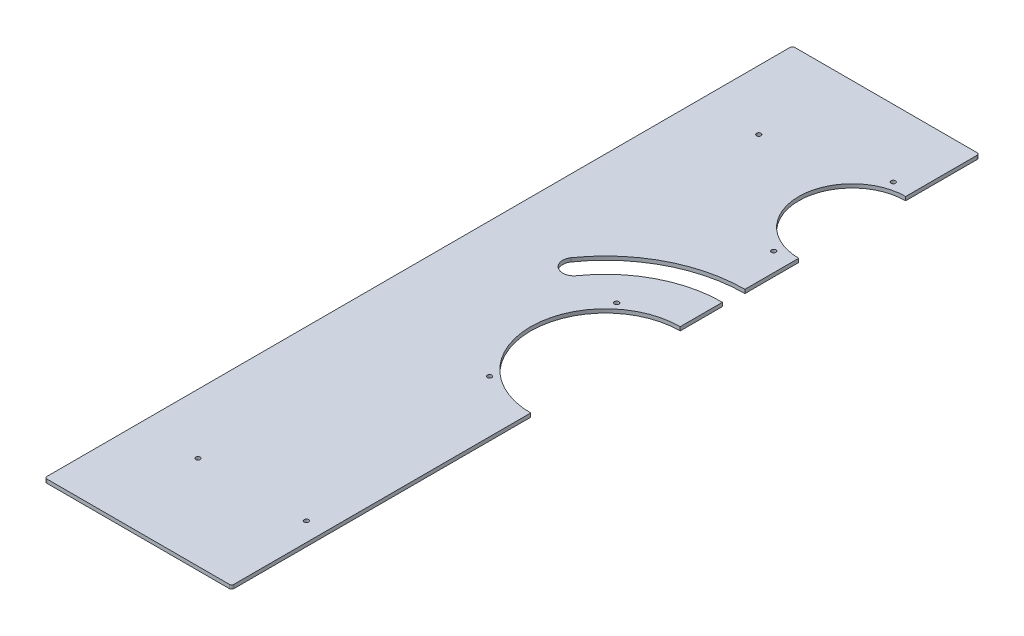
from build123d import *

# Parameters (mm, degrees)
SKETCH1_W           = 250
SKETCH1_H           = 1000
BOSS_EXTRUDE1_DEPTH = 5
FILLET1_R           = 3
CUT_EXTRUDE2_REACH  = 7
SKETCH3_R           = 71.5
SKETCH3_R_2         = 100
SKETCH3_R_3         = 3


with BuildPart() as part:
    # Sketch1 → Boss-Extrude1 (new body)
    with BuildSketch(Plane(origin=(0, 0, 0), x_dir=(1, 0, 0), z_dir=(0, 1, 0))):
        Rectangle(SKETCH1_W, SKETCH1_H)
    extrude(amount=BOSS_EXTRUDE1_DEPTH)

    # Fillet1
    fillet1_edges = [part.edges().sort_by_distance(p)[0] for p in [
        (125, 2.5, 500),
        (-125, 2.5, 500),
        (-125, 2.5, -500),
        (125, 2.5, -500),
    ]]
    fillet(fillet1_edges, radius=FILLET1_R)

    # Sketch3 → Cut-Extrude2 (cut, up to next)
    with BuildSketch(Plane(origin=(0, 5, 0), x_dir=(1, 0, 0), z_dir=(0, 1, 0)), mode=Mode.PRIVATE) as cut_extrude2_sk1:
        with Locations((125, 330)):
            Circle(SKETCH3_R)
    cut_extrude2_tool1 = extrude(cut_extrude2_sk1.sketch, amount=-CUT_EXTRUDE2_REACH, mode=Mode.PRIVATE) & part.part
    add(cut_extrude2_tool1.solids().sort_by_distance((125, 5, -330))[0], mode=Mode.SUBTRACT)
    # Sketch3 → Cut-Extrude2 (cut, up to next)
    with BuildSketch(Plane(origin=(0, 5, 0), x_dir=(1, 0, 0), z_dir=(0, 1, 0)), mode=Mode.PRIVATE) as cut_extrude2_sk2:
        with Locations((125, 0)):
            Circle(SKETCH3_R_2)
    cut_extrude2_tool2 = extrude(cut_extrude2_sk2.sketch, amount=-CUT_EXTRUDE2_REACH, mode=Mode.PRIVATE) & part.part
    add(cut_extrude2_tool2.solids().sort_by_distance((125, 5, 0))[0], mode=Mode.SUBTRACT)
    # Sketch3 → Cut-Extrude2 (cut, up to next)
    with BuildSketch(Plane(origin=(0, 5, 0), x_dir=(1, 0, 0), z_dir=(0, 1, 0)), mode=Mode.PRIVATE) as cut_extrude2_sk3:
        with Locations((-45, -375)):
            Circle(SKETCH3_R_3)
    cut_extrude2_tool3 = extrude(cut_extrude2_sk3.sketch, amount=-CUT_EXTRUDE2_REACH, mode=Mode.PRIVATE) & part.part
    add(cut_extrude2_tool3.solids().sort_by_distance((-45, 5, 375))[0], mode=Mode.SUBTRACT)
    # Sketch3 → Cut-Extrude2 (cut, up to next)
    with BuildSketch(Plane(origin=(0, 5, 0), x_dir=(1, 0, 0), z_dir=(0, 1, 0)), mode=Mode.PRIVATE) as cut_extrude2_sk4:
        with Locations((-45, 375)):
            Circle(SKETCH3_R_3)
    cut_extrude2_tool4 = extrude(cut_extrude2_sk4.sketch, amount=-CUT_EXTRUDE2_REACH, mode=Mode.PRIVATE) & part.part
    add(cut_extrude2_tool4.solids().sort_by_distance((-45, 5, -375))[0], mode=Mode.SUBTRACT)
    # Sketch3 → Cut-Extrude2 (cut, up to next)
    with BuildSketch(Plane(origin=(0, 5, 0), x_dir=(1, 0, 0), z_dir=(0, 1, 0)), mode=Mode.PRIVATE) as cut_extrude2_sk5:
        with Locations((55, -85)):
            Circle(SKETCH3_R_3)
    cut_extrude2_tool5 = extrude(cut_extrude2_sk5.sketch, amount=-CUT_EXTRUDE2_REACH, mode=Mode.PRIVATE) & part.part
    add(cut_extrude2_tool5.solids().sort_by_distance((55, 5, 85))[0], mode=Mode.SUBTRACT)
    # Sketch3 → Cut-Extrude2 (cut, up to next)
    with BuildSketch(Plane(origin=(0, 5, 0), x_dir=(1, 0, 0), z_dir=(0, 1, 0)), mode=Mode.PRIVATE) as cut_extrude2_sk6:
        with Locations((55, 85)):
            Circle(SKETCH3_R_3)
    cut_extrude2_tool6 = extrude(cut_extrude2_sk6.sketch, amount=-CUT_EXTRUDE2_REACH, mode=Mode.PRIVATE) & part.part
    add(cut_extrude2_tool6.solids().sort_by_distance((55, 5, -85))[0], mode=Mode.SUBTRACT)
    # Sketch3 → Cut-Extrude2 (cut, up to next)
    with BuildSketch(Plane(origin=(0, 5, 0), x_dir=(1, 0, 0), z_dir=(0, 1, 0)), mode=Mode.PRIVATE) as cut_extrude2_sk7:
        with Locations((100, 410)):
            Circle(SKETCH3_R_3)
    cut_extrude2_tool7 = extrude(cut_extrude2_sk7.sketch, amount=-CUT_EXTRUDE2_REACH, mode=Mode.PRIVATE) & part.part
    add(cut_extrude2_tool7.solids().sort_by_distance((100, 5, -410))[0], mode=Mode.SUBTRACT)
    # Sketch3 → Cut-Extrude2 (cut, up to next)
    with BuildSketch(Plane(origin=(0, 5, 0), x_dir=(1, 0, 0), z_dir=(0, 1, 0)), mode=Mode.PRIVATE) as cut_extrude2_sk8:
        with Locations((100, 250)):
            Circle(SKETCH3_R_3)
    cut_extrude2_tool8 = extrude(cut_extrude2_sk8.sketch, amount=-CUT_EXTRUDE2_REACH, mode=Mode.PRIVATE) & part.part
    add(cut_extrude2_tool8.solids().sort_by_distance((100, 5, -250))[0], mode=Mode.SUBTRACT)
    # Sketch3 → Cut-Extrude2 (cut, up to next)
    with BuildSketch(Plane(origin=(0, 5, 0), x_dir=(1, 0, 0), z_dir=(0, 1, 0)), mode=Mode.PRIVATE) as cut_extrude2_sk9:
        with Locations((100, -375)):
            Circle(SKETCH3_R_3)
    cut_extrude2_tool9 = extrude(cut_extrude2_sk9.sketch, amount=-CUT_EXTRUDE2_REACH, mode=Mode.PRIVATE) & part.part
    add(cut_extrude2_tool9.solids().sort_by_distance((100, 5, 375))[0], mode=Mode.SUBTRACT)
    # Sketch3 → Cut-Extrude2 (cut, up to next)
    with BuildSketch(Plane(origin=(0, 5, 0), x_dir=(1, 0, 0), z_dir=(0, 1, 0)), mode=Mode.PRIVATE) as cut_extrude2_sk10:
        with BuildLine():
            ThreePointArc((125, 186.5), (38.883883632, 165.427520388), (-27.77185626, 106.972005379))
            ThreePointArc((-27.77185626, 106.972005379), (-24.088222141, 86.08107817), (-3.197294931, 89.764712289))
            ThreePointArc((-3.197294931, 89.764712289), (52.736342029, 138.817195392), (125, 156.5))
            ThreePointArc((125, 156.5), (140, 171.5), (125, 186.5))
        make_face()
    cut_extrude2_tool10 = extrude(cut_extrude2_sk10.sketch, amount=-CUT_EXTRUDE2_REACH, mode=Mode.PRIVATE) & part.part
    add(cut_extrude2_tool10.solids().sort_by_distance((49.559691, 5, -144.919486))[0], mode=Mode.SUBTRACT)


solid = part.part
